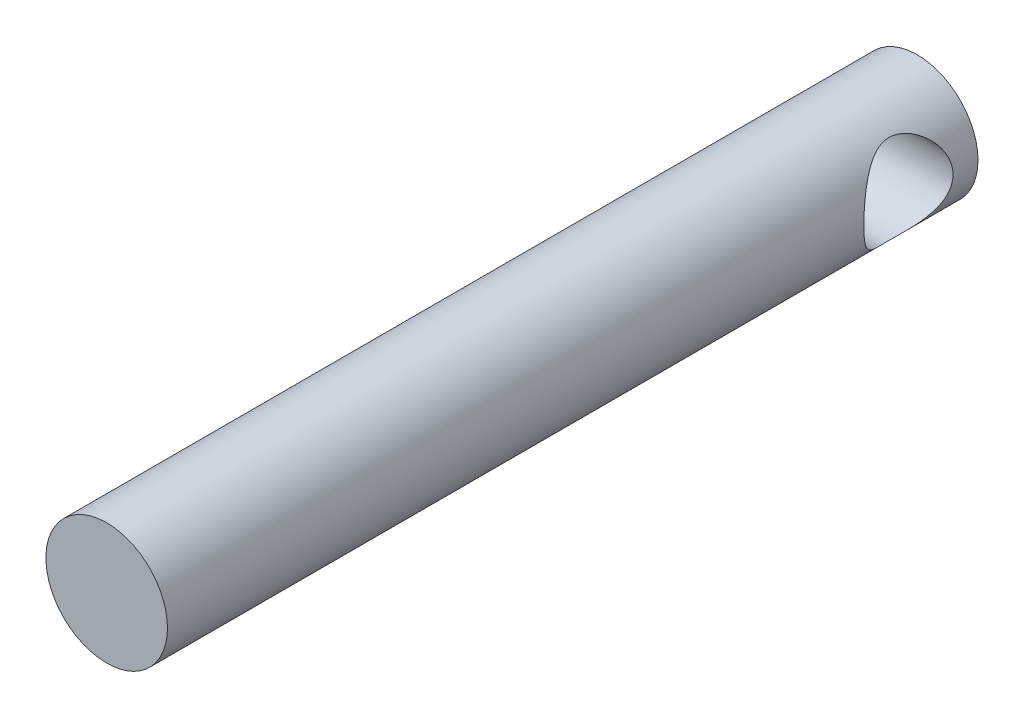
from build123d import *

# Parameters (mm, degrees)
SKETCH1_R               = 7.5
BOSS_EXTRUDE1_DEPTH     = 100
SKETCH2_R               = 5.5
CUT_EXTRUDE1_DEPTH      = 8.5
CUT_EXTRUDE1_DEPTH_BACK = 8.5


with BuildPart() as part:
    # Sketch1 → Boss-Extrude1 (new body)
    with BuildSketch(Plane.XY):
        Circle(SKETCH1_R)
    extrude(amount=BOSS_EXTRUDE1_DEPTH)

    # Sketch2 → Cut-Extrude1 (cut, two sides)
    with BuildSketch(Plane(origin=(0, 0, 0), x_dir=(0, 0, -1), z_dir=(1, 0, 0))) as cut_extrude1_sk:
        with Locations((-8.585970475, 0)):
            Circle(SKETCH2_R)
    extrude(amount=CUT_EXTRUDE1_DEPTH, mode=Mode.SUBTRACT)
    extrude(cut_extrude1_sk.sketch, amount=-CUT_EXTRUDE1_DEPTH_BACK, mode=Mode.SUBTRACT)


solid = part.part
